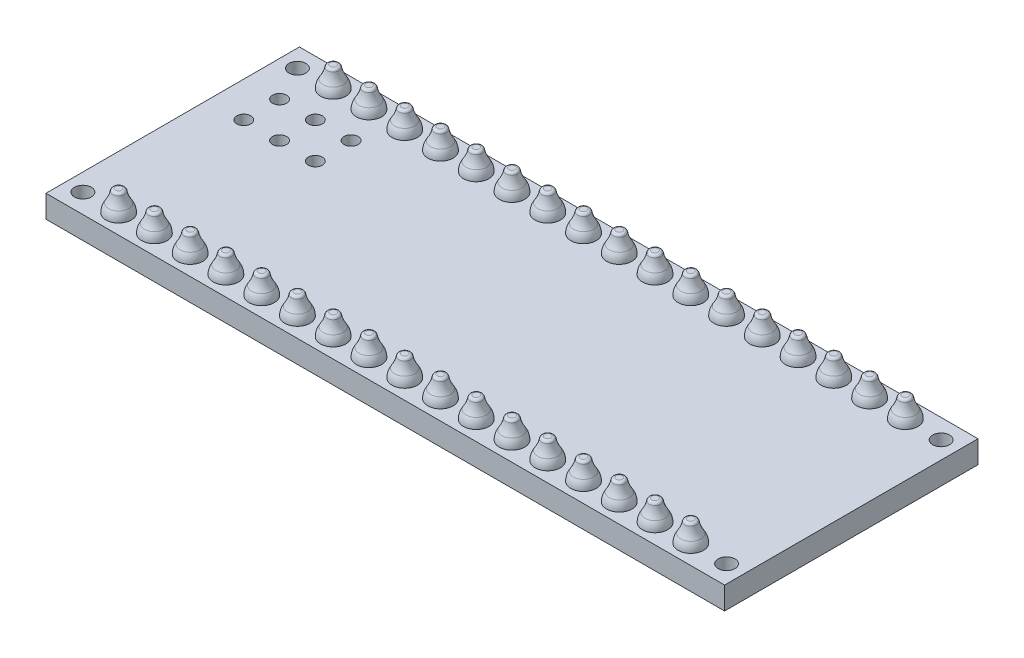
from build123d import *

# Parameters (mm, degrees)
SKETCH1_W            = 48.2
SKETCH1_H            = 18
SKETCH1_R            = 0.6
BOSS_EXTRUDE2_DEPTH  = 1.6
SKETCH2_R            = 0.45
CUT_EXTRUDE2_DEPTH   = 1.6
LPATTERN1_COUNT      = 17
LPATTERN1_PITCH      = 2.54
SKETCH3_R            = 0.5
CUT_EXTRUDE4_DEPTH   = 1.6
LPATTERN2_COUNT      = 2
LPATTERN2_PITCH      = 15.24
LPATTERN2_COUNT_DIR2 = 17
LPATTERN2_PITCH_DIR2 = 2.54
LPATTERN3_COUNT      = 2
LPATTERN3_PITCH      = 2.54
LPATTERN3_COUNT_DIR2 = 3
LPATTERN3_PITCH_DIR2 = 2.54


with BuildPart() as part:
    # Sketch1 → Boss-Extrude2 (new body)
    with BuildSketch(Plane(origin=(0, 0, 0), x_dir=(1, 0, 0), z_dir=(0, 1, 0))):
        with Locations((20.32, 7.62)):
            Rectangle(SKETCH1_W, SKETCH1_H)
        with Locations((-2.54, 0)):
            Circle(SKETCH1_R, mode=Mode.SUBTRACT)
        with Locations((-2.54, 15.24)):
            Circle(SKETCH1_R, mode=Mode.SUBTRACT)
        with Locations((43.18, 15.24)):
            Circle(SKETCH1_R, mode=Mode.SUBTRACT)
        with Locations((43.18, 0)):
            Circle(SKETCH1_R, mode=Mode.SUBTRACT)
    extrude(amount=BOSS_EXTRUDE2_DEPTH)

    # Sketch2 → Cut-Extrude2 (cut)
    with BuildSketch(Plane(origin=(0, 0, 0), x_dir=(1, 0, 0), z_dir=(0, 1, 0))):
        Circle(SKETCH2_R)
        with Locations((0, 15.24)):
            Circle(SKETCH2_R)
    cut_extrude2 = extrude(amount=CUT_EXTRUDE2_DEPTH, mode=Mode.SUBTRACT)

    # LPattern1: Cut-Extrude2 ×17
    with Locations(*[(i * LPATTERN1_PITCH, 0, 0) for i in range(1, LPATTERN1_COUNT)]):
        add(cut_extrude2, mode=Mode.SUBTRACT)

    # Sketch3 → Cut-Extrude4 (cut)
    with BuildSketch(Plane(origin=(0, 0, 0), x_dir=(1, 0, 0), z_dir=(0, 1, 0))):
        with Locations((1.27, 12.7)):
            Circle(SKETCH3_R)
        with Locations((-1.27, 12.7)):
            Circle(SKETCH3_R)
        with Locations((-1.27, 10.16)):
            Circle(SKETCH3_R)
        with Locations((3.81, 12.7)):
            Circle(SKETCH3_R)
        with Locations((3.81, 10.16)):
            Circle(SKETCH3_R)
        with Locations((1.27, 10.16)):
            Circle(SKETCH3_R)
    extrude(amount=CUT_EXTRUDE4_DEPTH, mode=Mode.SUBTRACT)

    # Sketch6 → Revolve1 (revolve)
    with BuildSketch(Plane(origin=(0, 0, 0), x_dir=(0, 0, -1), z_dir=(1, 0, 0))):
        with BuildLine():
            Line((0, 1.6), (0.9, 1.6))
            ThreePointArc((0.9, 1.6), (0.852442497, 1.91994498), (0.713882199, 2.212224898))
            ThreePointArc((0.713882199, 2.212224898), (0.530499248, 2.558589224), (0.422081551, 2.93520993))
            ThreePointArc((0.422081551, 2.93520993), (0.353575878, 3.053365554), (0.225205293, 3.1))
            Line((0.225205293, 3.1), (0, 3.1))
            Line((0, 3.1), (0, 1.6))
        make_face()
    revolve1 = revolve(axis=Axis((0, 1.372239532, 0), (0, 1, 0)))

    # LPattern2: Revolve1 2 × 17
    with Locations(*[(j * LPATTERN2_PITCH_DIR2, 0, -i * LPATTERN2_PITCH) for i in range(LPATTERN2_COUNT) for j in range(LPATTERN2_COUNT_DIR2) if (i, j) != (0, 0)]):
        add(revolve1)

    # Sketch7 → Revolve2 (revolve)
    with BuildSketch(Plane.XY.offset(-10.16)):
        with BuildLine():
            Line((-1.27, 0), (-0.37, 0))
            ThreePointArc((-0.37, 0), (-0.426448372, -0.347850543), (-0.59, -0.66))
            ThreePointArc((-0.59, -0.66), (-0.767825445, -0.974977034), (-0.859019438, -1.325))
            ThreePointArc((-0.859019438, -1.325), (-0.925163221, -1.45), (-1.057450787, -1.5))
            Line((-1.057450787, -1.5), (-1.27, -1.5))
            Line((-1.27, -1.5), (-1.27, 0))
        make_face()
    revolve2 = revolve(axis=Axis((-1.27, 3.888986093, -10.16), (0, -1, 0)))

    # LPattern3: Revolve2 2 × 3
    with Locations(*[(j * LPATTERN3_PITCH_DIR2, 0, -i * LPATTERN3_PITCH) for i in range(LPATTERN3_COUNT) for j in range(LPATTERN3_COUNT_DIR2) if (i, j) != (0, 0)]):
        add(revolve2)


solid = part.part
